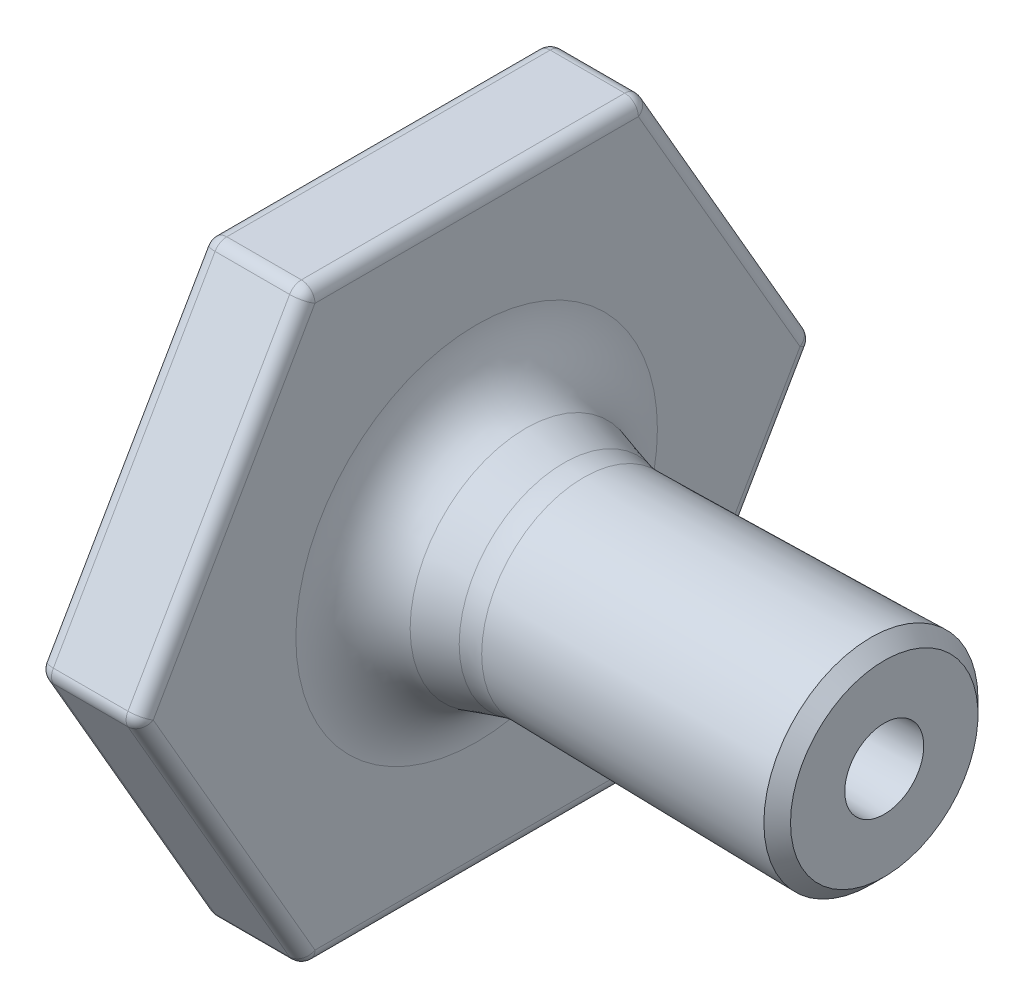
from build123d import *

# Parameters (mm, degrees)
FILLET4_R               = 3
CHAMFER1_SIZE2          = 0.393197641
CHAMFER1_SIZE           = 0.4
CUT_EXTRUDE1_DEPTH      = 13.023098533
CUT_EXTRUDE1_DEPTH_BACK = 8.0000001
FILLET5_R               = 0.4
FILLET6_R               = 2


with BuildPart() as part:
    # Sketch1 → Revolve1 (revolve)
    with BuildSketch(Plane.XY):
        Polygon((0, 1.825), (6.718918331, 1.825), (9.596035247, 1), (19.023098433, 1.16455), (19.023098433, 3.164854656), (9.859986912, 3.00491195), (7, 3.825), (7, 10), (4, 10), (4, 2.625), (0, 2.625), align=None)
    revolve(axis=Axis((0, 0, 0), (1, 0, 0)))

    # Fillet4
    fillet4_edges = [part.edges().sort_by_distance(p)[0] for p in [
        (9.596035247, -1, 0),
        (6.718918331, -1.825, 0),
    ]]
    fillet(fillet4_edges, radius=FILLET4_R)

    # Chamfer1
    chamfer1_edges = [part.edges().sort_by_distance(p)[0] for p in [
        (19.023098433, -3.164854656, 0),
    ]]
    chamfer(chamfer1_edges, length=CHAMFER1_SIZE, length2=CHAMFER1_SIZE2)

    # Sketch2 → Cut-Extrude1 (cut, two sides)
    with BuildSketch(Plane(origin=(7, 0, 0), x_dir=(0, 0, -1), z_dir=(1, 0, 0))) as cut_extrude1_sk:
        with BuildLine():
            Line((-10, 0), (-5, 8.660254038))
            ThreePointArc((-5, 8.660254038), (-8.660254038, 5), (-10, 0))
        make_face()
        with BuildLine():
            Line((-5, 8.660254038), (5, 8.660254038))
            ThreePointArc((5, 8.660254038), (0, 10), (-5, 8.660254038))
        make_face()
        with BuildLine():
            Line((5, 8.660254038), (10, 0))
            ThreePointArc((10, 0), (8.660254038, 5), (5, 8.660254038))
        make_face()
        with BuildLine():
            ThreePointArc((-10, 0), (-8.660254038, -5), (-5, -8.660254038))
            Line((-5, -8.660254038), (-10, 0))
        make_face()
        with BuildLine():
            ThreePointArc((-5, -8.660254038), (0, -10), (5, -8.660254038))
            Line((5, -8.660254038), (-5, -8.660254038))
        make_face()
        with BuildLine():
            ThreePointArc((5, -8.660254038), (8.660254038, -5), (10, 0))
            Line((10, 0), (5, -8.660254038))
        make_face()
    extrude(amount=CUT_EXTRUDE1_DEPTH, mode=Mode.SUBTRACT)
    extrude(cut_extrude1_sk.sketch, amount=-CUT_EXTRUDE1_DEPTH_BACK, mode=Mode.SUBTRACT)

    # Fillet5
    fillet5_edges = [part.edges().sort_by_distance(p)[0] for p in [
        (7, -4.330127019, -7.5),
        (4, -4.330127019, -7.5),
        (4, -8.660254038, 0),
        (4, 4.330127019, -7.5),
        (4, 4.330127019, 7.5),
        (5.5, 8.660254038, 5),
        (7, 4.330127019, 7.5),
        (5.5, 0, 10),
        (5.5, 0, -10),
        (7, 4.330127019, -7.5),
        (5.5, 8.660254038, -5),
        (5.5, -8.660254038, 5),
        (7, -8.660254038, 0),
        (5.5, -8.660254038, -5),
        (7, 8.660254038, 0),
        (4, 8.660254038, 0),
        (7, -4.330127019, 7.5),
        (4, -4.330127019, 7.5),
    ]]
    fillet(fillet5_edges, radius=FILLET5_R)

    # Fillet6
    fillet6_edges = [part.edges().sort_by_distance(p)[0] for p in [
        (7, -3.825, 0),
        (9.859986912, -3.00491195, 0),
    ]]
    fillet(fillet6_edges, radius=FILLET6_R)


solid = part.part
